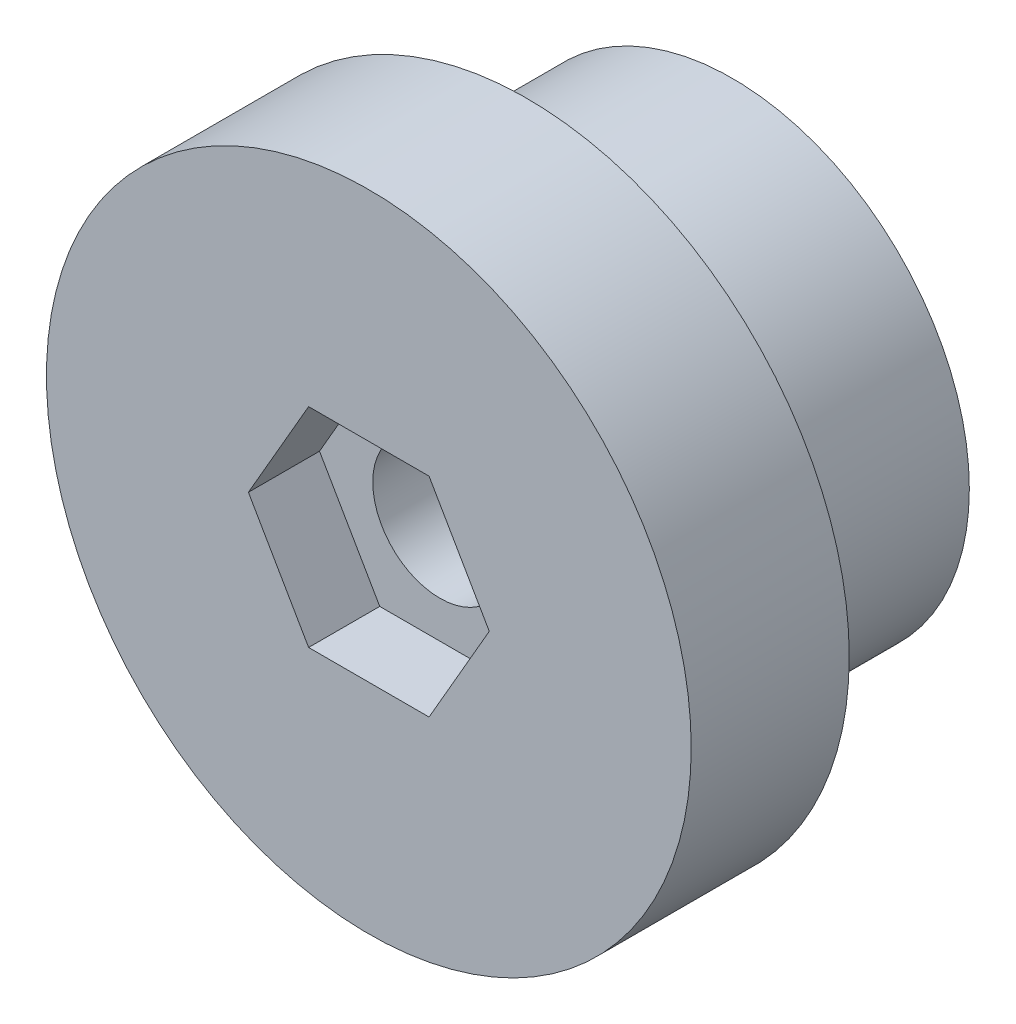
from build123d import *

# Parameters (mm, degrees)
ESBO_O1_R                = 20.4
ESBO_O1_R_2              = 4.25
RESSALTO_EXTRUS_O1_DEPTH = 10
CORTE_EXTRUS_O1_DEPTH    = 4.5
ESBO_O5_R                = 15
ESBO_O5_R_2              = 4.25
RESSALTO_EXTRUS_O2_DEPTH = 13


with BuildPart() as part:
    # Esboço1 → Ressalto-extrusão1 (new body)
    with BuildSketch(Plane.XY):
        Circle(ESBO_O1_R)
        Circle(ESBO_O1_R_2, mode=Mode.SUBTRACT)
    extrude(amount=RESSALTO_EXTRUS_O1_DEPTH)

    # Esboço2 → Corte-extrusão1 (cut)
    with BuildSketch(Plane.XY.offset(10)):
        Polygon((3.810511777, -6.6), (7.621023553, 0), (3.810511777, 6.6), (-3.810511777, 6.6), (-7.621023553, 0), (-3.810511777, -6.6), align=None)
    extrude(amount=-CORTE_EXTRUS_O1_DEPTH, mode=Mode.SUBTRACT)

    # Esboço5 → Ressalto-extrusão2 (add)
    with BuildSketch(Plane(origin=(0, 0, 0), x_dir=(-1, 0, 0), z_dir=(0, 0, -1))):
        Circle(ESBO_O5_R)
        Circle(ESBO_O5_R_2, mode=Mode.SUBTRACT)
    extrude(amount=RESSALTO_EXTRUS_O2_DEPTH)


solid = part.part
